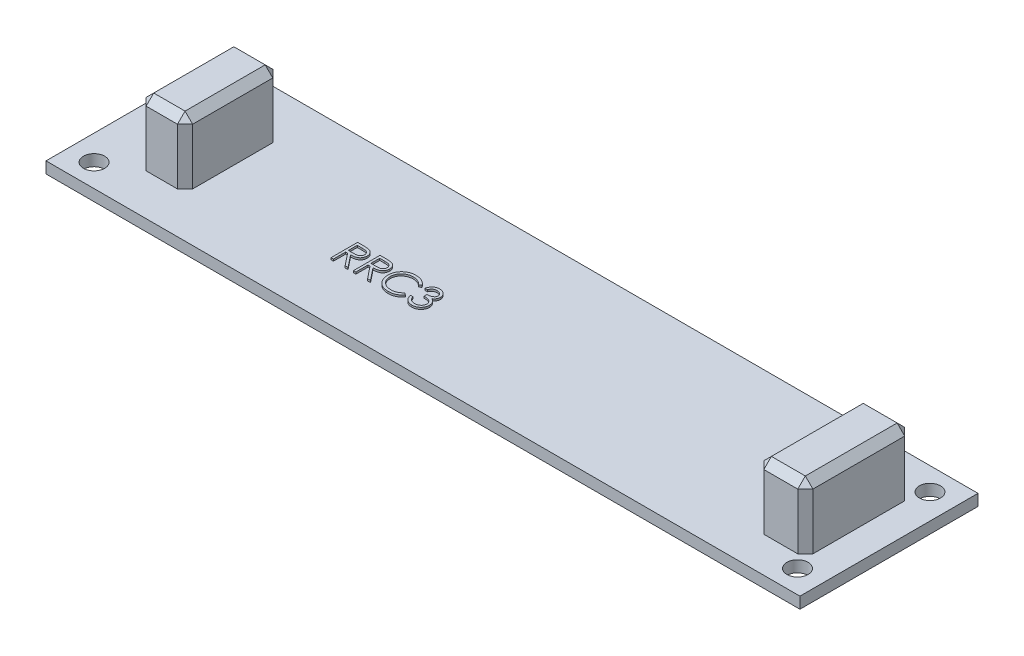
from build123d import *

# Parameters (mm, degrees)
SKETCH1_W           = 99.5
SKETCH1_H           = 23.5
SKETCH1_R           = 1.397
BOSS_EXTRUDE1_DEPTH = 1.5
SKETCH2_W           = 6.478221764
SKETCH2_H           = 14.11883515
SKETCH2_W_2         = 6.135718808
SKETCH2_H_2         = 12.574368932
BOSS_EXTRUDE2_DEPTH = 8.4
CHAMFER1_SIZE       = 1
BOSS_EXTRUDE3_DEPTH = 0.25


with BuildPart() as part:
    # Sketch1 → Boss-Extrude1 (new body)
    with BuildSketch(Plane(origin=(0, 0, 0), x_dir=(1, 0, 0), z_dir=(0, 1, 0))):
        with Locations((49.75, 11.75)):
            Rectangle(SKETCH1_W, SKETCH1_H)
        with Locations((3.33, 20.49)):
            Circle(SKETCH1_R, mode=Mode.SUBTRACT)
        with Locations((96.17, 20.49)):
            Circle(SKETCH1_R, mode=Mode.SUBTRACT)
        with Locations((96.17, 3.01)):
            Circle(SKETCH1_R, mode=Mode.SUBTRACT)
        with Locations((3.33, 3.01)):
            Circle(SKETCH1_R, mode=Mode.SUBTRACT)
    extrude(amount=BOSS_EXTRUDE1_DEPTH)

    # Sketch2 → Boss-Extrude2 (add)
    with BuildSketch(Plane(origin=(0, 1.5, 0), x_dir=(1, 0, 0), z_dir=(0, 1, 0))):
        with Locations((92.282983354, 11.75)):
            Rectangle(SKETCH2_W, SKETCH2_H)
        with Locations((9.821413832, 11.75)):
            Rectangle(SKETCH2_W_2, SKETCH2_H_2)
    extrude(amount=BOSS_EXTRUDE2_DEPTH)

    # Chamfer1
    chamfer1_edges = [part.edges().sort_by_distance(p)[0] for p in [
        (12.889273236, 5.7, -5.462815534),
        (12.889273236, 5.7, -18.037184466),
        (6.753554428, 5.7, -18.037184466),
        (6.753554428, 5.7, -5.462815534),
        (12.889273236, 9.9, -11.75),
        (9.821413832, 9.9, -18.037184466),
        (6.753554428, 9.9, -11.75),
        (9.821413832, 9.9, -5.462815534),
        (95.522094236, 5.7, -4.690582425),
        (95.522094236, 5.7, -18.809417575),
        (89.043872472, 5.7, -18.809417575),
        (89.043872472, 5.7, -4.690582425),
        (95.522094236, 9.9, -11.75),
        (92.282983354, 9.9, -18.809417575),
        (89.043872472, 9.9, -11.75),
        (92.282983354, 9.9, -4.690582425),
    ]]
    chamfer(chamfer1_edges, length=CHAMFER1_SIZE)

    # Sketch3 → Boss-Extrude3 (add)
    with BuildSketch(Plane(origin=(0, 1.5, 0), x_dir=(1, 0, 0), z_dir=(0, 1, 0))):
        with BuildLine():
            Line((30.124053321, 10.998038475), (30.824473994, 10.998038475))
            add(Edge.make_bspline(
                [(30.824473994, 10.998038475), (30.871215123, 10.997882889), (30.960963267, 10.997584147), (31.089536537, 10.995918384), (31.206363634, 10.991144028), (31.311383474, 10.987035444), (31.404594129, 10.979543503), (31.48628142, 10.972382856), (31.556069117, 10.963009195), (31.598314968, 10.954303772), (31.617442744, 10.950362193)],
                knots=[0, 0, 0, 0, 0.000140226, 0.00026925, 0.000385712, 0.000490995, 0.000584507, 0.000666202, 0.000736998, 0.000795574, 0.000795574, 0.000795574, 0.000795574], degree=3))
            add(Edge.make_bspline(
                [(31.617442744, 10.950362193), (31.643049368, 10.944035427), (31.693716358, 10.931516864), (31.766666424, 10.905057263), (31.836180748, 10.874437638), (31.901970572, 10.838473918), (31.963706363, 10.796899138), (32.022024674, 10.750431016), (32.077190137, 10.69932381), (32.126971768, 10.642288969), (32.173910819, 10.582452459), (32.213499446, 10.517748702), (32.247625926, 10.450087175), (32.274796443, 10.378779757), (32.296674416, 10.304517985), (32.312100655, 10.226629188), (32.321351843, 10.145468213), (32.322293699, 10.090110304), (32.32277127, 10.062040879)],
                knots=[0, 0, 0, 0, 7.9081e-05, 0.000156475, 0.000232432, 0.000306798, 0.00038108, 0.000455429, 0.000530331, 0.000606314, 0.000682321, 0.000758201, 0.000833453, 0.000909362, 0.000986794, 0.001065445, 0.001147284, 0.001231465, 0.001231465, 0.001231465, 0.001231465], degree=3))
            add(Edge.make_bspline(
                [(32.32277127, 10.062040879), (32.321302272, 10.015405774), (32.318435876, 9.924408606), (32.291710772, 9.792347725), (32.247934253, 9.66915841), (32.187610964, 9.554995772), (32.110791488, 9.452085127), (32.018466697, 9.361694672), (31.910585085, 9.286054759), (31.810155769, 9.233601954), (31.72144157, 9.200009046), (31.648408257, 9.176372687), (31.568741279, 9.158110722), (31.483203945, 9.14175059), (31.391440289, 9.129398895), (31.29367025, 9.120352301), (31.189824098, 9.114698252), (31.118485029, 9.113856247), (31.081785693, 9.11342309)],
                knots=[0, 0, 0, 0, 0.000139777, 0.000272741, 0.000402249, 0.000530843, 0.000658588, 0.000786009, 0.000916741, 0.001052522, 0.001124656, 0.001201155, 0.001282612, 0.001369656, 0.001462366, 0.001560247, 0.001664165, 0.001774261, 0.001774261, 0.001774261, 0.001774261], degree=3))
            Line((31.081785693, 9.11342309), (32.367643065, 7.498038475))
            Line((32.367643065, 7.498038475), (31.97922159, 7.498038475))
            Line((31.97922159, 7.498038475), (30.693364219, 9.11342309))
            Line((30.693364219, 9.11342309), (30.438155885, 9.11342309))
            Line((30.438155885, 9.11342309), (30.438155885, 7.498038475))
            Line((30.438155885, 7.498038475), (30.124053321, 7.498038475))
            Line((30.124053321, 7.498038475), (30.124053321, 10.998038475))
        make_face()
        with BuildLine():
            Line((30.438155885, 10.639064116), (30.438155885, 9.472397449))
            Line((30.438155885, 9.472397449), (31.078981206, 9.467489597))
            add(Edge.make_bspline(
                [(31.078981206, 9.467489597), (31.108901245, 9.46747636), (31.166894802, 9.467450704), (31.250795467, 9.47144448), (31.328915578, 9.475987798), (31.40095633, 9.482937144), (31.466949906, 9.491893215), (31.526863319, 9.5030962), (31.580794371, 9.516148262), (31.643692909, 9.536349888), (31.713929441, 9.568355906), (31.790260901, 9.614921405), (31.855263238, 9.673490524), (31.910181101, 9.74046398), (31.954310532, 9.814100229), (31.985422586, 9.893516598), (32.005165029, 9.976708196), (32.007493574, 10.033886304), (32.008668706, 10.062742001)],
                knots=[0, 0, 0, 0, 8.9746e-05, 0.000173954, 0.000251933, 0.000324488, 0.000391021, 0.000451663, 0.000507268, 0.000557378, 0.000649639, 0.000738152, 0.000824558, 0.000910739, 0.000997194, 0.001080909, 0.00116578, 0.001252248, 0.001252248, 0.001252248, 0.001252248], degree=3))
            add(Edge.make_bspline(
                [(32.008668706, 10.062742001), (32.007466585, 10.090888574), (32.005084419, 10.146664813), (31.985635651, 10.228320723), (31.952746269, 10.305387673), (31.908424031, 10.377552158), (31.854424877, 10.443057894), (31.791107064, 10.499105047), (31.720201869, 10.545354512), (31.65393067, 10.574908892), (31.594696458, 10.593028746), (31.543266798, 10.605779909), (31.48515532, 10.616024378), (31.420079861, 10.624232439), (31.348318231, 10.631287384), (31.26950758, 10.636039162), (31.184170799, 10.638853026), (31.125023868, 10.638992115), (31.094405885, 10.639064116)],
                knots=[0, 0, 0, 0, 8.4371e-05, 0.000167192, 0.000250141, 0.000334794, 0.000420435, 0.000503871, 0.000587493, 0.000673488, 0.0007205, 0.000773215, 0.000832351, 0.0008974, 0.000969955, 0.001048634, 0.001134217, 0.001226067, 0.001226067, 0.001226067, 0.001226067], degree=3))
            Line((31.094405885, 10.639064116), (30.438155885, 10.639064116))
        make_face(mode=Mode.SUBTRACT)
        with BuildLine():
            Line((33.085591783, 10.998038475), (33.786012456, 10.998038475))
            add(Edge.make_bspline(
                [(33.786012456, 10.998038475), (33.832753584, 10.997882889), (33.922501729, 10.997584147), (34.051074999, 10.995918384), (34.167902096, 10.991144028), (34.272921935, 10.987035444), (34.36613259, 10.979543503), (34.447819881, 10.972382856), (34.517607579, 10.963009195), (34.55985343, 10.954303772), (34.578981206, 10.950362193)],
                knots=[0, 0, 0, 0, 0.000140226, 0.00026925, 0.000385712, 0.000490995, 0.000584507, 0.000666202, 0.000736998, 0.000795574, 0.000795574, 0.000795574, 0.000795574], degree=3))
            add(Edge.make_bspline(
                [(34.578981206, 10.950362193), (34.60458783, 10.944035427), (34.655254819, 10.931516864), (34.728204885, 10.905057263), (34.797719209, 10.874437638), (34.863509034, 10.838473918), (34.925244825, 10.796899138), (34.983563136, 10.750431016), (35.038728599, 10.69932381), (35.088510229, 10.642288969), (35.135449281, 10.582452459), (35.175037907, 10.517748702), (35.209164387, 10.450087175), (35.236334904, 10.378779757), (35.258212878, 10.304517985), (35.273639117, 10.226629188), (35.282890305, 10.145468213), (35.28383216, 10.090110304), (35.284309731, 10.062040879)],
                knots=[0, 0, 0, 0, 7.9081e-05, 0.000156475, 0.000232432, 0.000306798, 0.00038108, 0.000455429, 0.000530331, 0.000606314, 0.000682321, 0.000758201, 0.000833453, 0.000909362, 0.000986794, 0.001065445, 0.001147284, 0.001231465, 0.001231465, 0.001231465, 0.001231465], degree=3))
            add(Edge.make_bspline(
                [(35.284309731, 10.062040879), (35.282840733, 10.015405774), (35.279974337, 9.924408606), (35.253249234, 9.792347725), (35.209472714, 9.66915841), (35.149149425, 9.554995772), (35.072329949, 9.452085127), (34.980005158, 9.361694672), (34.872123547, 9.286054759), (34.771694231, 9.233601954), (34.682980031, 9.200009046), (34.609946718, 9.176372687), (34.530279741, 9.158110722), (34.444742406, 9.14175059), (34.352978751, 9.129398895), (34.255208711, 9.120352301), (34.15136256, 9.114698252), (34.08002349, 9.113856247), (34.043324154, 9.11342309)],
                knots=[0, 0, 0, 0, 0.000139777, 0.000272741, 0.000402249, 0.000530843, 0.000658588, 0.000786009, 0.000916741, 0.001052522, 0.001124656, 0.001201155, 0.001282612, 0.001369656, 0.001462366, 0.001560247, 0.001664165, 0.001774261, 0.001774261, 0.001774261, 0.001774261], degree=3))
            Line((34.043324154, 9.11342309), (35.329181526, 7.498038475))
            Line((35.329181526, 7.498038475), (34.940760052, 7.498038475))
            Line((34.940760052, 7.498038475), (33.65490268, 9.11342309))
            Line((33.65490268, 9.11342309), (33.399694347, 9.11342309))
            Line((33.399694347, 9.11342309), (33.399694347, 7.498038475))
            Line((33.399694347, 7.498038475), (33.085591783, 7.498038475))
            Line((33.085591783, 7.498038475), (33.085591783, 10.998038475))
        make_face()
        with BuildLine():
            Line((33.399694347, 10.639064116), (33.399694347, 9.472397449))
            Line((33.399694347, 9.472397449), (34.040519667, 9.467489597))
            add(Edge.make_bspline(
                [(34.040519667, 9.467489597), (34.070439706, 9.46747636), (34.128433263, 9.467450704), (34.212333928, 9.47144448), (34.29045404, 9.475987798), (34.362494792, 9.482937144), (34.428488367, 9.491893215), (34.488401781, 9.5030962), (34.542332832, 9.516148262), (34.605231371, 9.536349888), (34.675467902, 9.568355906), (34.751799362, 9.614921405), (34.8168017, 9.673490524), (34.871719562, 9.74046398), (34.915848994, 9.814100229), (34.946961048, 9.893516598), (34.96670349, 9.976708196), (34.969032036, 10.033886304), (34.970207167, 10.062742001)],
                knots=[0, 0, 0, 0, 8.9746e-05, 0.000173954, 0.000251933, 0.000324488, 0.000391021, 0.000451663, 0.000507268, 0.000557378, 0.000649639, 0.000738152, 0.000824558, 0.000910739, 0.000997194, 0.001080909, 0.00116578, 0.001252248, 0.001252248, 0.001252248, 0.001252248], degree=3))
            add(Edge.make_bspline(
                [(34.970207167, 10.062742001), (34.969005046, 10.090888574), (34.966622881, 10.146664813), (34.947174112, 10.228320723), (34.914284731, 10.305387673), (34.869962493, 10.377552158), (34.815963338, 10.443057894), (34.752645525, 10.499105047), (34.68174033, 10.545354512), (34.615469132, 10.574908892), (34.556234919, 10.593028746), (34.504805259, 10.605779909), (34.446693782, 10.616024378), (34.381618323, 10.624232439), (34.309856692, 10.631287384), (34.231046041, 10.636039162), (34.145709261, 10.638853026), (34.08656233, 10.638992115), (34.055944347, 10.639064116)],
                knots=[0, 0, 0, 0, 8.4371e-05, 0.000167192, 0.000250141, 0.000334794, 0.000420435, 0.000503871, 0.000587493, 0.000673488, 0.0007205, 0.000773215, 0.000832351, 0.0008974, 0.000969955, 0.001048634, 0.001134217, 0.001226067, 0.001226067, 0.001226067, 0.001226067], degree=3))
            Line((34.055944347, 10.639064116), (33.399694347, 10.639064116))
        make_face(mode=Mode.SUBTRACT)
        with BuildLine():
            Line((39.277899475, 10.355810911), (39.003059731, 10.145474372))
            add(Edge.make_bspline(
                [(39.003059731, 10.145474372), (38.983453843, 10.168840342), (38.944506396, 10.215257258), (38.881847194, 10.280436802), (38.816545551, 10.341502064), (38.74862643, 10.398743943), (38.67686731, 10.450160709), (38.603006511, 10.498431812), (38.525808466, 10.54169955), (38.419056732, 10.594162536), (38.279408883, 10.648908691), (38.103614044, 10.694811922), (37.920102946, 10.724033098), (37.794905346, 10.72719794), (37.731224795, 10.728807706)],
                knots=[0, 0, 0, 0, 9.1485e-05, 0.000181737, 0.000271024, 0.000359627, 0.000447979, 0.000535687, 0.000624217, 0.000713268, 0.000892422, 0.00107303, 0.001257466, 0.001448389, 0.001448389, 0.001448389, 0.001448389], degree=3))
            add(Edge.make_bspline(
                [(37.731224795, 10.728807706), (37.696141496, 10.728403743), (37.626300504, 10.727599567), (37.52265203, 10.716990442), (37.420938979, 10.702079232), (37.321227513, 10.679953909), (37.223644554, 10.65198129), (37.127552152, 10.618555876), (37.034341552, 10.577201036), (36.942723314, 10.531492776), (36.854944103, 10.479865331), (36.771889055, 10.423551979), (36.693861087, 10.363182883), (36.620798475, 10.298531777), (36.552626527, 10.229889816), (36.489839216, 10.156525474), (36.432653806, 10.078673301), (36.379936781, 9.997359893), (36.332724047, 9.912822102), (36.293194168, 9.824747031), (36.258189046, 9.734642928), (36.230489803, 9.641491767), (36.208565286, 9.545949002), (36.193437623, 9.447758214), (36.182949152, 9.347124534), (36.182148975, 9.278915221), (36.181745629, 9.244532866)],
                knots=[0, 0, 0, 0, 0.000105206, 0.000209435, 0.000312261, 0.00041348, 0.000515565, 0.000616682, 0.000718413, 0.000821258, 0.000923708, 0.001023662, 0.001122111, 0.001219464, 0.00131614, 0.001412112, 0.001508869, 0.001605718, 0.001702691, 0.001799013, 0.001895107, 0.001992482, 0.002090281, 0.00218895, 0.002290387, 0.00239349, 0.00239349, 0.00239349, 0.00239349], degree=3))
            add(Edge.make_bspline(
                [(36.181745629, 9.244532866), (36.183007448, 9.192801546), (36.185484862, 9.091233961), (36.207533196, 8.942463351), (36.241038287, 8.799942677), (36.291253864, 8.664562835), (36.353172915, 8.534654476), (36.431413526, 8.412415623), (36.522030064, 8.295999059), (36.626304483, 8.188156111), (36.740710299, 8.089642385), (36.863458211, 8.002891804), (36.994242499, 7.930576922), (37.131619129, 7.870400975), (37.276645243, 7.824144247), (37.429060045, 7.791580124), (37.58853204, 7.770337943), (37.69750144, 7.768304255), (37.752959571, 7.767269244)],
                knots=[0, 0, 0, 0, 0.000155106, 0.000304531, 0.000450265, 0.000593548, 0.000736853, 0.000881182, 0.001028026, 0.001178769, 0.001330408, 0.001480379, 0.001628835, 0.001777978, 0.001929641, 0.002084627, 0.002245075, 0.00241136, 0.00241136, 0.00241136, 0.00241136], degree=3))
            add(Edge.make_bspline(
                [(37.752959571, 7.767269244), (37.81406226, 7.768958024), (37.934326969, 7.772281946), (38.110694995, 7.800441196), (38.279530761, 7.846099113), (38.440843348, 7.909997036), (38.594177994, 7.993062324), (38.739774654, 8.093760201), (38.877756225, 8.213048534), (38.960727507, 8.304131662), (39.003059731, 8.350602577)],
                knots=[0, 0, 0, 0, 0.00018322, 0.00036062, 0.000534275, 0.000707044, 0.000879893, 0.001056289, 0.001237208, 0.001425665, 0.001425665, 0.001425665, 0.001425665], degree=3))
            Line((39.003059731, 8.350602577), (39.277899475, 8.142369404))
            add(Edge.make_bspline(
                [(39.277899475, 8.142369404), (39.255781365, 8.113830952), (39.21165109, 8.056890746), (39.140193073, 7.976619036), (39.064915775, 7.901115001), (38.985260065, 7.83098738), (38.902142274, 7.764832914), (38.814069962, 7.704531083), (38.722200929, 7.649240199), (38.62684645, 7.598613274), (38.528107837, 7.553696027), (38.426103402, 7.515242259), (38.321272827, 7.48211737), (38.213611318, 7.454865433), (38.102895562, 7.433594349), (37.989525088, 7.419374674), (37.873255212, 7.40963276), (37.794813791, 7.408744844), (37.755062937, 7.408294885)],
                knots=[0, 0, 0, 0, 0.000108293, 0.000216068, 0.000322162, 0.000427957, 0.000534281, 0.00064066, 0.000747915, 0.000855806, 0.000964371, 0.001073102, 0.001182643, 0.001294024, 0.001406092, 0.001520624, 0.001636667, 0.001755891, 0.001755891, 0.001755891, 0.001755891], degree=3))
            add(Edge.make_bspline(
                [(37.755062937, 7.408294885), (37.717419269, 7.408556878), (37.642983579, 7.409074936), (37.533084828, 7.417467103), (37.426095247, 7.42891684), (37.322320621, 7.446156971), (37.221194646, 7.466501311), (37.123634062, 7.493772568), (37.028678851, 7.524321734), (36.93671051, 7.560226721), (36.847650811, 7.600742903), (36.761786999, 7.646534462), (36.679158567, 7.697216327), (36.598953146, 7.751671337), (36.522355562, 7.811648639), (36.448702037, 7.876315274), (36.377579561, 7.945453285), (36.333576876, 7.995308138), (36.311453161, 8.020374212)],
                knots=[0, 0, 0, 0, 0.0001129, 0.000223246, 0.000330481, 0.000435603, 0.000538732, 0.000639764, 0.000739316, 0.000837878, 0.000935767, 0.001032686, 0.001129604, 0.00122645, 0.001323362, 0.001421241, 0.001520399, 0.001620667, 0.001620667, 0.001620667, 0.001620667], degree=3))
            add(Edge.make_bspline(
                [(36.311453161, 8.020374212), (36.276017517, 8.063915401), (36.205574041, 8.150472111), (36.115448357, 8.290758093), (36.038300802, 8.437226302), (35.975924881, 8.59064623), (35.927162148, 8.750673618), (35.893380953, 8.917389132), (35.871429348, 9.090637074), (35.86891906, 9.208473863), (35.867643065, 9.268371007)],
                knots=[0, 0, 0, 0, 0.000168306, 0.00033458, 0.000499224, 0.000664315, 0.00083066, 0.00100034, 0.001174094, 0.001353718, 0.001353718, 0.001353718, 0.001353718], degree=3))
            add(Edge.make_bspline(
                [(35.867643065, 9.268371007), (35.869198258, 9.33132646), (35.872258005, 9.455187385), (35.8982538, 9.636961338), (35.940072596, 9.811112737), (35.999469485, 9.977316482), (36.074774836, 10.136446762), (36.16780145, 10.287287967), (36.277468592, 10.430804766), (36.40291616, 10.564819518), (36.540483495, 10.68735887), (36.687802309, 10.795165074), (36.844584256, 10.88488259), (37.009102108, 10.959878753), (37.182587789, 11.017523216), (37.364671158, 11.057876402), (37.555010073, 11.082993519), (37.684872499, 11.086168727), (37.750856206, 11.087782065)],
                knots=[0, 0, 0, 0, 0.000188789, 0.000371431, 0.000549644, 0.000725278, 0.00089996, 0.001076844, 0.001255917, 0.001440951, 0.001626689, 0.001807878, 0.001987546, 0.002167657, 0.002349462, 0.002534866, 0.002726448, 0.002924344, 0.002924344, 0.002924344, 0.002924344], degree=3))
            add(Edge.make_bspline(
                [(37.750856206, 11.087782065), (37.791070678, 11.087299926), (37.870671175, 11.086345582), (37.988423827, 11.07703944), (38.103066154, 11.061525834), (38.214677136, 11.040409764), (38.323799753, 11.014202443), (38.429599993, 10.980062144), (38.53269868, 10.941025613), (38.632445588, 10.896067147), (38.728362139, 10.845600406), (38.820418457, 10.790184782), (38.907883316, 10.729888977), (38.991372164, 10.665225801), (39.069488375, 10.594827242), (39.144449854, 10.520629646), (39.213710932, 10.440495822), (39.256464127, 10.384090888), (39.277899475, 10.355810911)],
                knots=[0, 0, 0, 0, 0.000120626, 0.000238766, 0.000354085, 0.000467531, 0.000579423, 0.000690512, 0.000800803, 0.000910007, 0.001018518, 0.001125773, 0.001232152, 0.001337058, 0.001442329, 0.001547432, 0.001653292, 0.001759736, 0.001759736, 0.001759736, 0.001759736], degree=3))
        make_face()
        with BuildLine():
            Line((40.130463578, 10.190346167), (39.816361013, 10.190346167))
            add(Edge.make_bspline(
                [(39.816361013, 10.190346167), (39.824870564, 10.225578651), (39.84150604, 10.294455276), (39.876203613, 10.392862536), (39.914002868, 10.485986058), (39.959391973, 10.572082131), (40.008900727, 10.652881034), (40.065623449, 10.726550159), (40.126943171, 10.794963124), (40.194768121, 10.855676362), (40.265896782, 10.910654091), (40.341331402, 10.957529148), (40.419554296, 10.997853301), (40.501107429, 11.031073533), (40.5862336, 11.056099057), (40.674163224, 11.074255862), (40.765126724, 11.086046976), (40.826874314, 11.08719774), (40.858228001, 11.087782065)],
                knots=[0, 0, 0, 0, 0.000108665, 0.000212431, 0.000312691, 0.000409905, 0.000504067, 0.000596618, 0.000688443, 0.000779278, 0.000869306, 0.00095782, 0.001045306, 0.001133058, 0.001221569, 0.001311085, 0.001402223, 0.001496238, 0.001496238, 0.001496238, 0.001496238], degree=3))
            add(Edge.make_bspline(
                [(40.858228001, 11.087782065), (40.903910743, 11.086402834), (40.994279754, 11.083674459), (41.127042801, 11.058760022), (41.25506962, 11.01933489), (41.376958868, 10.964861163), (41.4901773, 10.89767385), (41.590913487, 10.817709113), (41.677801998, 10.726509811), (41.750696375, 10.625777247), (41.807771374, 10.518121738), (41.849857748, 10.407321581), (41.875479429, 10.293639609), (41.878799986, 10.21688233), (41.880463578, 10.178427097)],
                knots=[0, 0, 0, 0, 0.000136936, 0.000270885, 0.000403723, 0.000538055, 0.000670441, 0.000797677, 0.000922646, 0.001047185, 0.00116951, 0.001287103, 0.001401935, 0.001517226, 0.001517226, 0.001517226, 0.001517226], degree=3))
            add(Edge.make_bspline(
                [(41.880463578, 10.178427097), (41.879299986, 10.141420302), (41.877023019, 10.069003748), (41.857689314, 9.96328225), (41.825153051, 9.86364065), (41.780083288, 9.769659488), (41.721741738, 9.681934648), (41.651069041, 9.600268757), (41.567566379, 9.524299599), (41.504287441, 9.480780126), (41.471709571, 9.458375013)],
                knots=[0, 0, 0, 0, 0.000110957, 0.000217125, 0.000321111, 0.000424595, 0.000528824, 0.000636204, 0.000747885, 0.000866393, 0.000866393, 0.000866393, 0.000866393], degree=3))
            add(Edge.make_bspline(
                [(41.471709571, 9.458375013), (41.508941326, 9.440396842), (41.5827082, 9.404776884), (41.68325873, 9.334921127), (41.774536605, 9.254264779), (41.825440324, 9.191322126), (41.851016462, 9.159697129)],
                knots=[0, 0, 0, 0, 0.000123863, 0.000245408, 0.000366052, 0.000487879, 0.000487879, 0.000487879, 0.000487879], degree=3))
            add(Edge.make_bspline(
                [(41.851016462, 9.159697129), (41.867857805, 9.136639377), (41.901264701, 9.090901461), (41.942500234, 9.017365035), (41.979909349, 8.943013545), (42.009059568, 8.865854139), (42.031633435, 8.786781126), (42.047769467, 8.70565873), (42.057793608, 8.622420707), (42.05922916, 8.566108227), (42.059950757, 8.537802097)],
                knots=[0, 0, 0, 0, 8.5583e-05, 0.000169764, 0.000252544, 0.000335098, 0.000416766, 0.000498992, 0.000583001, 0.000667909, 0.000667909, 0.000667909, 0.000667909], degree=3))
            add(Edge.make_bspline(
                [(42.059950757, 8.537802097), (42.058156244, 8.488792375), (42.054575661, 8.391003574), (42.022571587, 8.246528852), (41.972958346, 8.10530335), (41.902501411, 7.97022851), (41.816633902, 7.843848129), (41.714476578, 7.73077182), (41.597190169, 7.633573216), (41.46638452, 7.552362988), (41.324667392, 7.487445066), (41.1730918, 7.442387623), (41.013841746, 7.413041623), (40.904634448, 7.409894754), (40.849113417, 7.408294885)],
                knots=[0, 0, 0, 0, 0.000146863, 0.000293035, 0.000441833, 0.000594857, 0.000748684, 0.000899086, 0.001050437, 0.001204129, 0.001359752, 0.001516561, 0.001677477, 0.001843893, 0.001843893, 0.001843893, 0.001843893], degree=3))
            add(Edge.make_bspline(
                [(40.849113417, 7.408294885), (40.811694117, 7.409163098), (40.738065412, 7.410871453), (40.629821914, 7.422550054), (40.526500214, 7.443880059), (40.427960616, 7.472583364), (40.33411558, 7.508975106), (40.245251475, 7.554293804), (40.160821581, 7.607605307), (40.08162263, 7.669538894), (40.007664062, 7.738820234), (39.940911338, 7.816679244), (39.880251545, 7.901676648), (39.827308906, 7.994799704), (39.779671954, 8.094844961), (39.740490997, 8.20309346), (39.706005429, 8.318577482), (39.689971964, 8.399055222), (39.681745629, 8.440346167)],
                knots=[0, 0, 0, 0, 0.000112258, 0.000220887, 0.000326076, 0.000428356, 0.000528479, 0.000627563, 0.000727152, 0.000827569, 0.00092875, 0.001030654, 0.001134734, 0.001241526, 0.001351611, 0.001466743, 0.00158655, 0.001712791, 0.001712791, 0.001712791, 0.001712791], degree=3))
            Line((39.681745629, 8.440346167), (39.995848193, 8.440346167))
            add(Edge.make_bspline(
                [(39.995848193, 8.440346167), (40.004031484, 8.413397154), (40.019948697, 8.360978982), (40.047042995, 8.285538677), (40.077911267, 8.216380623), (40.111025826, 8.152997501), (40.145804272, 8.094765099), (40.184719197, 8.04322323), (40.224888342, 7.996108028), (40.255167695, 7.969563416), (40.269986815, 7.956572129)],
                knots=[0, 0, 0, 0, 8.4487e-05, 0.000164335, 0.000240293, 0.00031148, 0.000378817, 0.000443461, 0.000505064, 0.000564113, 0.000564113, 0.000564113, 0.000564113], degree=3))
            add(Edge.make_bspline(
                [(40.269986815, 7.956572129), (40.289583391, 7.941463795), (40.328716054, 7.911293763), (40.392484285, 7.872792135), (40.459549171, 7.839431109), (40.531363846, 7.813947413), (40.606378616, 7.792369753), (40.685805981, 7.778249234), (40.768945198, 7.768561062), (40.825712962, 7.767706131), (40.854722392, 7.767269244)],
                knots=[0, 0, 0, 0, 7.418e-05, 0.000148131, 0.000223072, 0.000298488, 0.0003764, 0.000456984, 0.000540217, 0.000627201, 0.000627201, 0.000627201, 0.000627201], degree=3))
            add(Edge.make_bspline(
                [(40.854722392, 7.767269244), (40.887475894, 7.767885149), (40.951522541, 7.769089499), (41.044977401, 7.780165206), (41.133884848, 7.796295619), (41.217257774, 7.821208602), (41.296188281, 7.851989453), (41.369569931, 7.890637859), (41.438366037, 7.935982581), (41.501695442, 7.987521739), (41.55864095, 8.043943234), (41.608780463, 8.102956305), (41.651405125, 8.164312135), (41.685788703, 8.228350256), (41.712939253, 8.294805485), (41.731422454, 8.363864314), (41.744273969, 8.43496158), (41.745320581, 8.483290549), (41.745848193, 8.507653859)],
                knots=[0, 0, 0, 0, 9.822e-05, 0.00019206, 0.00028199, 0.000368957, 0.000452673, 0.000535779, 0.000617257, 0.000699492, 0.000780303, 0.000857417, 0.000931514, 0.001003978, 0.001075065, 0.001146335, 0.001218144, 0.001291145, 0.001291145, 0.001291145, 0.001291145], degree=3))
            add(Edge.make_bspline(
                [(41.745848193, 8.507653859), (41.744317891, 8.540265198), (41.741264903, 8.605325607), (41.717956323, 8.701043181), (41.679617459, 8.793266593), (41.625944948, 8.880422383), (41.560609219, 8.961198285), (41.484244312, 9.033269767), (41.396216084, 9.092739858), (41.315196215, 9.133828515), (41.243431059, 9.16186559), (41.182015674, 9.180540555), (41.113259071, 9.19635421), (41.037992722, 9.211066482), (40.955649505, 9.22358783), (40.866319067, 9.234029646), (40.769983306, 9.242384687), (40.70329214, 9.246115782), (40.668925116, 9.248038475)],
                knots=[0, 0, 0, 0, 9.7761e-05, 0.000195035, 0.000293731, 0.000396299, 0.00050098, 0.000604654, 0.000710058, 0.000818548, 0.000876487, 0.000941025, 0.001010919, 0.001088059, 0.001171055, 0.001260716, 0.001357836, 0.001461094, 0.001461094, 0.001461094, 0.001461094], degree=3))
            Line((40.668925116, 9.248038475), (40.668925116, 9.607012834))
            add(Edge.make_bspline(
                [(40.668925116, 9.607012834), (40.712226282, 9.607747638), (40.797042628, 9.609186938), (40.920936933, 9.626594948), (41.039410245, 9.650675576), (41.149836987, 9.687560768), (41.250485701, 9.730401065), (41.337805303, 9.780253275), (41.41057245, 9.835668024), (41.468433521, 9.897500633), (41.51196275, 9.963815681), (41.543789547, 10.032932338), (41.562589874, 10.105456399), (41.565099541, 10.154951067), (41.566361013, 10.17982934)],
                knots=[0, 0, 0, 0, 0.0001298, 0.000254247, 0.000374709, 0.000491998, 0.000602842, 0.000702416, 0.000792872, 0.000876214, 0.000955164, 0.001029842, 0.001103644, 0.00117823, 0.00117823, 0.00117823, 0.00117823], degree=3))
            add(Edge.make_bspline(
                [(41.566361013, 10.17982934), (41.565946602, 10.198107085), (41.565122152, 10.234469793), (41.554724874, 10.287594861), (41.539100833, 10.339095807), (41.517621103, 10.388753617), (41.488870905, 10.436223891), (41.454464918, 10.48191134), (41.413496818, 10.525555119), (41.366551371, 10.566235439), (41.316139566, 10.605004676), (41.260889791, 10.637918313), (41.202467916, 10.666063375), (41.140809261, 10.689272877), (41.075713731, 10.706732165), (41.007487173, 10.719268007), (40.93599949, 10.727105661), (40.887227758, 10.728234077), (40.862434731, 10.728807706)],
                knots=[0, 0, 0, 0, 5.4759e-05, 0.000108941, 0.000161726, 0.000216044, 0.000270754, 0.000327825, 0.00038735, 0.000449943, 0.000514025, 0.000577874, 0.000642472, 0.000708366, 0.000775209, 0.000844379, 0.000916308, 0.00099068, 0.00099068, 0.00099068, 0.00099068], degree=3))
            add(Edge.make_bspline(
                [(40.862434731, 10.728807706), (40.822583063, 10.727416344), (40.744743487, 10.72469869), (40.63252857, 10.700895677), (40.528209236, 10.662917593), (40.448470569, 10.617584574), (40.389587995, 10.57283414), (40.347511057, 10.533751753), (40.306190547, 10.49031893), (40.26834487, 10.439860555), (40.230070893, 10.385793764), (40.195226332, 10.325370083), (40.161366639, 10.260165688), (40.14096409, 10.214070054), (40.130463578, 10.190346167)],
                knots=[0, 0, 0, 0, 0.00011944, 0.000233294, 0.000342435, 0.0004514, 0.000506931, 0.000563998, 0.000623523, 0.000686492, 0.000753006, 0.000822147, 0.000895524, 0.000973336, 0.000973336, 0.000973336, 0.000973336], degree=3))
        make_face()
    extrude(amount=BOSS_EXTRUDE3_DEPTH)


solid = part.part
